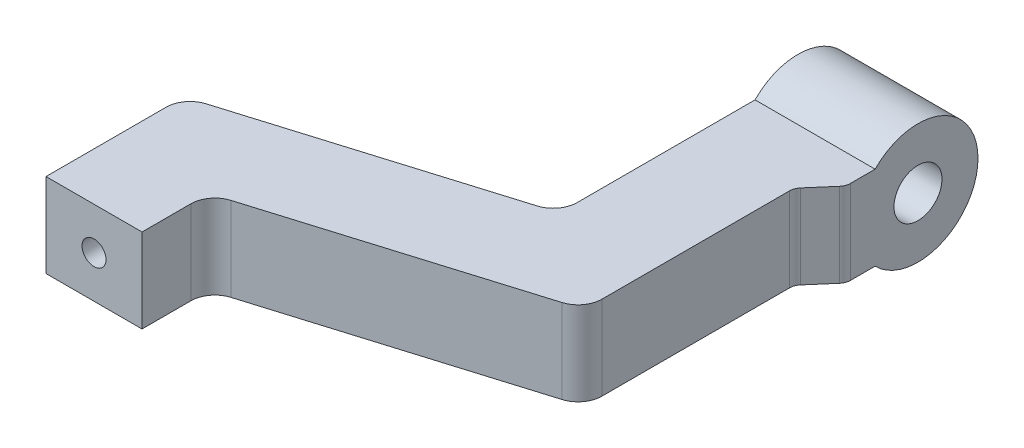
from build123d import *

# Parameters (mm, degrees)
BOSS_EXTRUDE2_DEPTH = 3.5
SKETCH3_R           = 2.5
BOSS_EXTRUDE3_DEPTH = 5
FILLET2_R           = 0.5
SKETCH5_R           = 0.5
CUT_EXTRUDE1_DEPTH  = 1
SKETCH6_R           = 1
CUT_EXTRUDE2_DEPTH  = 6


with BuildPart() as part:
    # Sketch2 → Boss-Extrude2 (new body)
    with BuildSketch(Plane(origin=(0, 0, 0), x_dir=(1, 0, 0), z_dir=(0, 1, 0))):
        with BuildLine():
            Line((-1.500662684, 17.128376176), (-1.500662684, 12.128376176))
            Line((-1.500662684, 12.128376176), (2.499337316, 12.128376176))
            Line((2.499337316, 12.128376176), (2.499337316, 14.162218976))
            ThreePointArc((2.499337316, 14.162218976), (2.696087031, 14.75786063), (3.208915276, 15.119117632))
            Line((3.208915276, 15.119117632), (13.789759356, 18.330440279))
            ThreePointArc((13.789759356, 18.330440279), (14.302587601, 18.691697281), (14.499337316, 19.287338935))
            Line((14.499337316, 19.287338935), (14.499337316, 27.287338935))
            Line((14.499337316, 27.287338935), (15.499337316, 28.444539704))
            Line((15.499337316, 28.444539704), (15.499337316, 28.878255261))
            Line((15.499337316, 28.878255261), (15.499337316, 31.444539704))
            Line((15.499337316, 31.444539704), (10.499337316, 31.444539704))
            Line((10.499337316, 31.444539704), (10.499337316, 26.210120497))
            Line((10.499337316, 26.210120497), (10.499337316, 22.253496135))
            ThreePointArc((10.499337316, 22.253496135), (10.302587601, 21.657854481), (9.789759356, 21.296597478))
            Line((9.789759356, 21.296597478), (-0.791084724, 18.085274832))
            ThreePointArc((-0.791084724, 18.085274832), (-1.303912969, 17.724017829), (-1.500662684, 17.128376176))
        make_face()
    extrude(amount=BOSS_EXTRUDE2_DEPTH)

    # Sketch3 → Boss-Extrude3 (add)
    with BuildSketch(Plane.ZY.offset(-10.499337316)):
        with Locations((-31.444539704, 1.75)):
            Circle(SKETCH3_R)
    extrude(amount=-BOSS_EXTRUDE3_DEPTH)

    # Fillet2
    fillet2_edges = [part.edges().sort_by_distance(p)[0] for p in [
        (15.499337316, 1.75, -28.444539704),
        (14.499337316, 1.75, -27.287338935),
    ]]
    fillet(fillet2_edges, radius=FILLET2_R)

    # Sketch5 → Cut-Extrude1 (cut)
    with BuildSketch(Plane.XY.offset(-12.128376176)):
        with Locations((0.499337316, 1.75)):
            Circle(SKETCH5_R)
    extrude(amount=-CUT_EXTRUDE1_DEPTH, mode=Mode.SUBTRACT)

    # Sketch6 → Cut-Extrude2 (cut, through all)
    with BuildSketch(Plane.ZY.offset(-10.499337316)):
        with Locations((-31.444539704, 1.75)):
            Circle(SKETCH6_R)
    extrude(amount=-CUT_EXTRUDE2_DEPTH, mode=Mode.SUBTRACT)


solid = part.part
